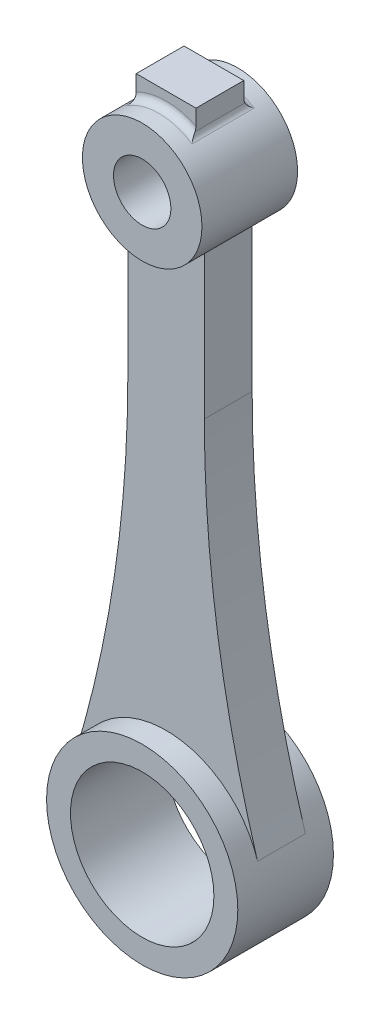
from build123d import *

# Parameters (mm, degrees)
SKETCH3_R             = 20
SKETCH3_R_2           = 15
BOSS_EXTRUDE3_DEPTH   = 10
SKETCH3_R_3           = 12.5
SKETCH3_R_4           = 6
BOSS_EXTRUDE3_2_DEPTH = 10
BOSS_EXTRUDE4_DEPTH   = 5
BOSS_EXTRUDE5_DEPTH   = 5
FILLET1_R             = 1.5


with BuildPart() as part:
    # Sketch3 → Boss-Extrude3 (new body, symmetric)
    with BuildSketch(Plane.XY):
        Circle(SKETCH3_R)
        Circle(SKETCH3_R_2, mode=Mode.SUBTRACT)
    extrude(amount=BOSS_EXTRUDE3_DEPTH, both=True)



with BuildPart() as body_2:
    # Sketch3 → Boss-Extrude3 2 (new body, symmetric)
    with BuildSketch(Plane.XY):
        with Locations((0, 120)):
            Circle(SKETCH3_R_3)
        with Locations((0, 120)):
            Circle(SKETCH3_R_4, mode=Mode.SUBTRACT)
    extrude(amount=BOSS_EXTRUDE3_2_DEPTH, both=True)


with BuildPart() as part_1:
    add(part.part)

    add(body_2.part)  # Boss-Extrude4 merges body 2
    # Sketch4 → Boss-Extrude4 (add, symmetric)
    with BuildSketch(Plane.XY):
        with BuildLine():
            Line((8, 110.395313644), (8, 80.395313644))
            ThreePointArc((8, 80.395313644), (10.797388085, 42.704875811), (19.128250996, 5.840377886))
            ThreePointArc((19.128250996, 5.840377886), (0, 20), (-19.128250996, 5.840377886))
            ThreePointArc((-19.128250996, 5.840377886), (-10.797388085, 42.704875811), (-8, 80.395313644))
            Line((-8, 80.395313644), (-8, 110.395313644))
            ThreePointArc((-8, 110.395313644), (0, 107.5), (8, 110.395313644))
        make_face()
    extrude(amount=BOSS_EXTRUDE4_DEPTH, both=True)

    # Sketch5 → Boss-Extrude5 (add, symmetric)
    with BuildSketch(Plane.XY):
        with BuildLine():
            Line((-6.25, 135.825317547), (-6.25, 130.825317547))
            ThreePointArc((-6.25, 130.825317547), (0, 132.5), (6.25, 130.825317547))
            Line((6.25, 130.825317547), (6.25, 135.825317547))
            Line((6.25, 135.825317547), (-6.25, 135.825317547))
        make_face()
    extrude(amount=BOSS_EXTRUDE5_DEPTH, both=True)

    # Fillet1
    fillet1_edges = [part_1.edges().sort_by_distance(p)[0] for p in [
        (0, 132.5, -5),
        (-6.25, 130.825317547, 0),
        (6.25, 130.825317547, 0),
        (0, 132.5, 5),
    ]]
    fillet(fillet1_edges, radius=FILLET1_R)


solid = part_1.part
